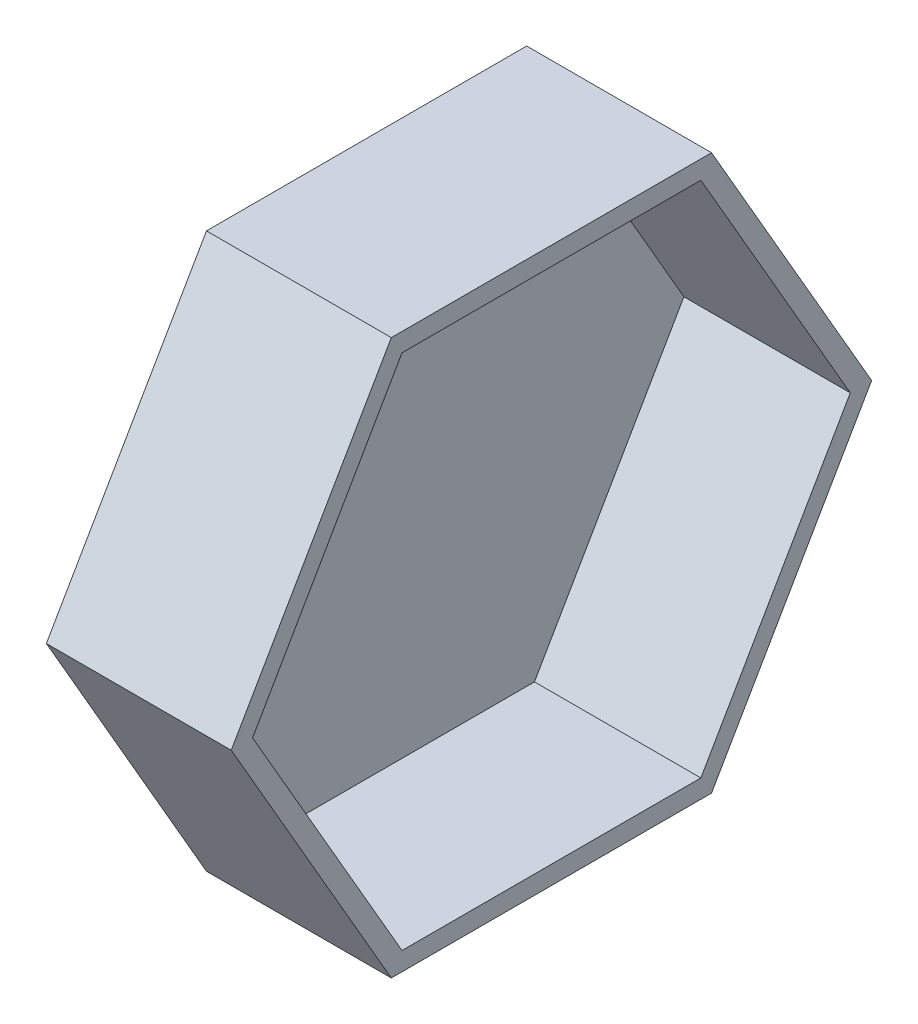
from build123d import *

# Parameters (mm, degrees)
RESSALTO_EXTRUS_O1_DEPTH = 50
CASCA1_T                 = -10


with BuildPart() as part:
    # Esboço1 → Ressalto-extrusão1 (new body, symmetric)
    with BuildSketch(Plane(origin=(0, 0, 0), x_dir=(0, 0, -1), z_dir=(1, 0, 0))):
        Polygon((173.205080757, 0), (86.602540378, 150), (-86.602540378, 150), (-173.205080757, 0), (-86.602540378, -150), (86.602540378, -150), align=None)
    extrude(amount=RESSALTO_EXTRUS_O1_DEPTH, both=True)

    # Casca1
    casca1_openings = [part.faces().sort_by_distance(p)[0] for p in [
        (50, 0, 0),
    ]]
    offset(amount=CASCA1_T, openings=casca1_openings, kind=Kind.INTERSECTION)


solid = part.part
